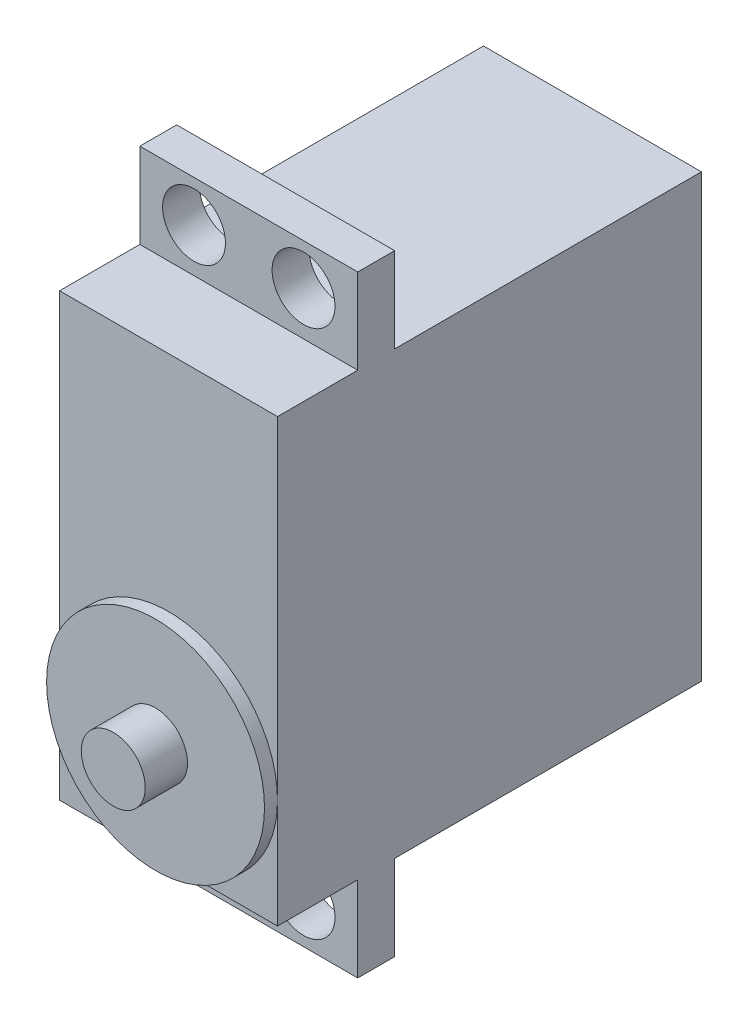
from build123d import *

# Parameters (mm, degrees)
EXTRUDE_1_DEPTH     = 39.1
SKETCH_7_R          = 10.05
EXTRUDE_2_DEPTH     = 1.2
SKETCH_9_R          = 2.95
EXTRUDE_3_DEPTH     = 3.9
SKETCH_10_W         = 20.1
SKETCH_10_H         = 3.4
EXTRUDE_4_DEPTH     = 7.85
SKETCH_11_W         = 20.1
SKETCH_11_H         = 3.4
EXTRUDE_5_DEPTH     = 7.85
CUT_EXTRUDE_1_REACH = 45.602
CUT_EXTRUDE_2_REACH = 45.602


with BuildPart() as part:
    # Sketch 3D_2 → 凸台-拉伸1 (new body)
    with BuildSketch(Plane(origin=(-10.05, 20.35, 0), x_dir=(0.4428021776174894, -0.8966193347777024, 0), z_dir=(0, 0, 1))):
        Polygon((0, 0), (8.90032377, 18.022048629), (45.392730696, 0), (36.492406925, -18.022048629), align=None)
    extrude(amount=-EXTRUDE_1_DEPTH)

    # 草图7 → 凸台-拉伸2 (add)
    with BuildSketch(Plane.XY):
        with Locations((0, -10.3)):
            Circle(SKETCH_7_R)
    extrude(amount=EXTRUDE_2_DEPTH)

    # 草图9 → 凸台-拉伸3 (add)
    with BuildSketch(Plane.XY.offset(1.2)):
        with Locations((0, -10.3)):
            Circle(SKETCH_9_R)
    extrude(amount=EXTRUDE_3_DEPTH)

    # 草图10 → 凸台-拉伸4 (add)
    with BuildSketch(Plane.XZ.offset(20.35)):
        with Locations((0, -9.1)):
            Rectangle(SKETCH_10_W, SKETCH_10_H)
    extrude(amount=EXTRUDE_4_DEPTH)

    # 草图11 → 凸台-拉伸5 (add)
    with BuildSketch(Plane(origin=(0, 20.35, 0), x_dir=(1, 0, 0), z_dir=(0, 1, 0))):
        with Locations((0, 9.1)):
            Rectangle(SKETCH_11_W, SKETCH_11_H)
    extrude(amount=EXTRUDE_5_DEPTH)

    # 草图13 → 切除-拉伸1 (cut, up to next)
    with BuildSketch(Plane.XY.offset(-7.4), mode=Mode.PRIVATE) as cut_extrude_1_sk1:
        with BuildLine():
            ThreePointArc((-7.95, -24.4), (-7.100609665, -26.450609665), (-5.05, -27.3))
            Line((-5.05, -27.3), (-5.05, -24.4))
            Line((-5.05, -24.4), (-7.95, -24.4))
        make_face()
    cut_extrude_1_tool1 = extrude(cut_extrude_1_sk1.sketch, amount=-CUT_EXTRUDE_1_REACH, mode=Mode.PRIVATE) & part.part
    # 草图13 → 切除-拉伸1 (cut, up to next)
    with BuildSketch(Plane.XY.offset(-7.4), mode=Mode.PRIVATE) as cut_extrude_1_sk2:
        with BuildLine():
            Line((-5.05, -24.4), (-5.05, -27.3))
            ThreePointArc((-5.05, -27.3), (-2.999390335, -26.450609665), (-2.15, -24.4))
            ThreePointArc((-2.15, -24.4), (-5.05, -21.5), (-7.95, -24.4))
            Line((-7.95, -24.4), (-5.05, -24.4))
        make_face()
    cut_extrude_1_tool2 = extrude(cut_extrude_1_sk2.sketch, amount=-CUT_EXTRUDE_1_REACH, mode=Mode.PRIVATE) & part.part
    # 草图13 → 切除-拉伸1 (cut, up to next)
    with BuildSketch(Plane.XY.offset(-7.4), mode=Mode.PRIVATE) as cut_extrude_1_sk3:
        with BuildLine():
            ThreePointArc((-7.95, -24.4), (-7.100609665, -26.450609665), (-5.05, -27.3))
            Line((-5.05, -27.3), (-5.05, -24.4))
            Line((-5.05, -24.4), (-7.95, -24.4))
        make_face()
    cut_extrude_1_tool3 = extrude(cut_extrude_1_sk3.sketch, amount=-CUT_EXTRUDE_1_REACH, mode=Mode.PRIVATE) & part.part
    # 草图13 → 切除-拉伸1 (cut, up to next)
    with BuildSketch(Plane.XY.offset(-7.4), mode=Mode.PRIVATE) as cut_extrude_1_sk4:
        with BuildLine():
            Line((-5.05, -24.4), (-5.05, -27.3))
            ThreePointArc((-5.05, -27.3), (-2.999390335, -26.450609665), (-2.15, -24.4))
            ThreePointArc((-2.15, -24.4), (-5.05, -21.5), (-7.95, -24.4))
            Line((-7.95, -24.4), (-5.05, -24.4))
        make_face()
    cut_extrude_1_tool4 = extrude(cut_extrude_1_sk4.sketch, amount=-CUT_EXTRUDE_1_REACH, mode=Mode.PRIVATE) & part.part
    # 草图13 → 切除-拉伸1 (cut, up to next)
    with BuildSketch(Plane.XY.offset(-7.4), mode=Mode.PRIVATE) as cut_extrude_1_sk5:
        with BuildLine():
            ThreePointArc((7.95, -24.4), (2.999390335, -22.349390335), (5.05, -27.3))
            Line((5.05, -27.3), (5.05, -24.4))
            Line((5.05, -24.4), (7.95, -24.4))
        make_face()
    cut_extrude_1_tool5 = extrude(cut_extrude_1_sk5.sketch, amount=-CUT_EXTRUDE_1_REACH, mode=Mode.PRIVATE) & part.part
    # 草图13 → 切除-拉伸1 (cut, up to next)
    with BuildSketch(Plane.XY.offset(-7.4), mode=Mode.PRIVATE) as cut_extrude_1_sk6:
        with BuildLine():
            Line((5.05, -24.4), (5.05, -27.3))
            ThreePointArc((5.05, -27.3), (7.100609665, -26.450609665), (7.95, -24.4))
            Line((7.95, -24.4), (5.05, -24.4))
        make_face()
    cut_extrude_1_tool6 = extrude(cut_extrude_1_sk6.sketch, amount=-CUT_EXTRUDE_1_REACH, mode=Mode.PRIVATE) & part.part
    # 草图13 → 切除-拉伸1 (cut, up to next)
    with BuildSketch(Plane.XY.offset(-7.4), mode=Mode.PRIVATE) as cut_extrude_1_sk7:
        with BuildLine():
            ThreePointArc((7.95, -24.4), (2.999390335, -22.349390335), (5.05, -27.3))
            Line((5.05, -27.3), (5.05, -24.4))
            Line((5.05, -24.4), (7.95, -24.4))
        make_face()
    cut_extrude_1_tool7 = extrude(cut_extrude_1_sk7.sketch, amount=-CUT_EXTRUDE_1_REACH, mode=Mode.PRIVATE) & part.part
    # 草图13 → 切除-拉伸1 (cut, up to next)
    with BuildSketch(Plane.XY.offset(-7.4), mode=Mode.PRIVATE) as cut_extrude_1_sk8:
        with BuildLine():
            Line((5.05, -24.4), (5.05, -27.3))
            ThreePointArc((5.05, -27.3), (7.100609665, -26.450609665), (7.95, -24.4))
            Line((7.95, -24.4), (5.05, -24.4))
        make_face()
    cut_extrude_1_tool8 = extrude(cut_extrude_1_sk8.sketch, amount=-CUT_EXTRUDE_1_REACH, mode=Mode.PRIVATE) & part.part
    add(cut_extrude_1_tool1.solids().sort_by_distance((-6.280798, -25.630798, -7.4))[0], mode=Mode.SUBTRACT)
    add(cut_extrude_1_tool2.solids().sort_by_distance((-4.639734, -23.989734, -7.4))[0], mode=Mode.SUBTRACT)
    add(cut_extrude_1_tool3.solids().sort_by_distance((-6.280798, -25.630798, -7.4))[0], mode=Mode.SUBTRACT)
    add(cut_extrude_1_tool4.solids().sort_by_distance((-4.639734, -23.989734, -7.4))[0], mode=Mode.SUBTRACT)
    add(cut_extrude_1_tool5.solids().sort_by_distance((4.639734, -23.989734, -7.4))[0], mode=Mode.SUBTRACT)
    add(cut_extrude_1_tool6.solids().sort_by_distance((6.280798, -25.630798, -7.4))[0], mode=Mode.SUBTRACT)
    add(cut_extrude_1_tool7.solids().sort_by_distance((4.639734, -23.989734, -7.4))[0], mode=Mode.SUBTRACT)
    add(cut_extrude_1_tool8.solids().sort_by_distance((6.280798, -25.630798, -7.4))[0], mode=Mode.SUBTRACT)

    # 草图14 → 切除-拉伸2 (cut, up to next)
    with BuildSketch(Plane.XY.offset(-7.4), mode=Mode.PRIVATE) as cut_extrude_2_sk1:
        with BuildLine():
            ThreePointArc((-2.15, 24.4), (-2.999390335, 26.450609665), (-5.05, 27.3))
            Line((-5.05, 27.3), (-5.05, 24.4))
            Line((-5.05, 24.4), (-7.95, 24.4))
            ThreePointArc((-7.95, 24.4), (-5.05, 21.5), (-2.15, 24.4))
        make_face()
    cut_extrude_2_tool1 = extrude(cut_extrude_2_sk1.sketch, amount=-CUT_EXTRUDE_2_REACH, mode=Mode.PRIVATE) & part.part
    # 草图14 → 切除-拉伸2 (cut, up to next)
    with BuildSketch(Plane.XY.offset(-7.4), mode=Mode.PRIVATE) as cut_extrude_2_sk2:
        with BuildLine():
            Line((-5.05, 24.4), (-5.05, 27.3))
            ThreePointArc((-5.05, 27.3), (-7.100609665, 26.450609665), (-7.95, 24.4))
            Line((-7.95, 24.4), (-5.05, 24.4))
        make_face()
    cut_extrude_2_tool2 = extrude(cut_extrude_2_sk2.sketch, amount=-CUT_EXTRUDE_2_REACH, mode=Mode.PRIVATE) & part.part
    # 草图14 → 切除-拉伸2 (cut, up to next)
    with BuildSketch(Plane.XY.offset(-7.4), mode=Mode.PRIVATE) as cut_extrude_2_sk3:
        with BuildLine():
            ThreePointArc((-2.15, 24.4), (-2.999390335, 26.450609665), (-5.05, 27.3))
            Line((-5.05, 27.3), (-5.05, 24.4))
            Line((-5.05, 24.4), (-7.95, 24.4))
            ThreePointArc((-7.95, 24.4), (-5.05, 21.5), (-2.15, 24.4))
        make_face()
    cut_extrude_2_tool3 = extrude(cut_extrude_2_sk3.sketch, amount=-CUT_EXTRUDE_2_REACH, mode=Mode.PRIVATE) & part.part
    # 草图14 → 切除-拉伸2 (cut, up to next)
    with BuildSketch(Plane.XY.offset(-7.4), mode=Mode.PRIVATE) as cut_extrude_2_sk4:
        with BuildLine():
            Line((-5.05, 24.4), (-5.05, 27.3))
            ThreePointArc((-5.05, 27.3), (-7.100609665, 26.450609665), (-7.95, 24.4))
            Line((-7.95, 24.4), (-5.05, 24.4))
        make_face()
    cut_extrude_2_tool4 = extrude(cut_extrude_2_sk4.sketch, amount=-CUT_EXTRUDE_2_REACH, mode=Mode.PRIVATE) & part.part
    # 草图14 → 切除-拉伸2 (cut, up to next)
    with BuildSketch(Plane.XY.offset(-7.4), mode=Mode.PRIVATE) as cut_extrude_2_sk5:
        with BuildLine():
            ThreePointArc((7.95, 24.4), (7.100609665, 26.450609665), (5.05, 27.3))
            Line((5.05, 27.3), (5.05, 24.4))
            Line((5.05, 24.4), (7.95, 24.4))
        make_face()
    cut_extrude_2_tool5 = extrude(cut_extrude_2_sk5.sketch, amount=-CUT_EXTRUDE_2_REACH, mode=Mode.PRIVATE) & part.part
    # 草图14 → 切除-拉伸2 (cut, up to next)
    with BuildSketch(Plane.XY.offset(-7.4), mode=Mode.PRIVATE) as cut_extrude_2_sk6:
        with BuildLine():
            Line((5.05, 24.4), (5.05, 27.3))
            ThreePointArc((5.05, 27.3), (2.999390335, 22.349390335), (7.95, 24.4))
            Line((7.95, 24.4), (5.05, 24.4))
        make_face()
    cut_extrude_2_tool6 = extrude(cut_extrude_2_sk6.sketch, amount=-CUT_EXTRUDE_2_REACH, mode=Mode.PRIVATE) & part.part
    # 草图14 → 切除-拉伸2 (cut, up to next)
    with BuildSketch(Plane.XY.offset(-7.4), mode=Mode.PRIVATE) as cut_extrude_2_sk7:
        with BuildLine():
            ThreePointArc((7.95, 24.4), (7.100609665, 26.450609665), (5.05, 27.3))
            Line((5.05, 27.3), (5.05, 24.4))
            Line((5.05, 24.4), (7.95, 24.4))
        make_face()
    cut_extrude_2_tool7 = extrude(cut_extrude_2_sk7.sketch, amount=-CUT_EXTRUDE_2_REACH, mode=Mode.PRIVATE) & part.part
    # 草图14 → 切除-拉伸2 (cut, up to next)
    with BuildSketch(Plane.XY.offset(-7.4), mode=Mode.PRIVATE) as cut_extrude_2_sk8:
        with BuildLine():
            Line((5.05, 24.4), (5.05, 27.3))
            ThreePointArc((5.05, 27.3), (2.999390335, 22.349390335), (7.95, 24.4))
            Line((7.95, 24.4), (5.05, 24.4))
        make_face()
    cut_extrude_2_tool8 = extrude(cut_extrude_2_sk8.sketch, amount=-CUT_EXTRUDE_2_REACH, mode=Mode.PRIVATE) & part.part
    add(cut_extrude_2_tool1.solids().sort_by_distance((-4.639734, 23.989734, -7.4))[0], mode=Mode.SUBTRACT)
    add(cut_extrude_2_tool2.solids().sort_by_distance((-6.280798, 25.630798, -7.4))[0], mode=Mode.SUBTRACT)
    add(cut_extrude_2_tool3.solids().sort_by_distance((-4.639734, 23.989734, -7.4))[0], mode=Mode.SUBTRACT)
    add(cut_extrude_2_tool4.solids().sort_by_distance((-6.280798, 25.630798, -7.4))[0], mode=Mode.SUBTRACT)
    add(cut_extrude_2_tool5.solids().sort_by_distance((6.280798, 25.630798, -7.4))[0], mode=Mode.SUBTRACT)
    add(cut_extrude_2_tool6.solids().sort_by_distance((4.639734, 23.989734, -7.4))[0], mode=Mode.SUBTRACT)
    add(cut_extrude_2_tool7.solids().sort_by_distance((6.280798, 25.630798, -7.4))[0], mode=Mode.SUBTRACT)
    add(cut_extrude_2_tool8.solids().sort_by_distance((4.639734, 23.989734, -7.4))[0], mode=Mode.SUBTRACT)


solid = part.part
